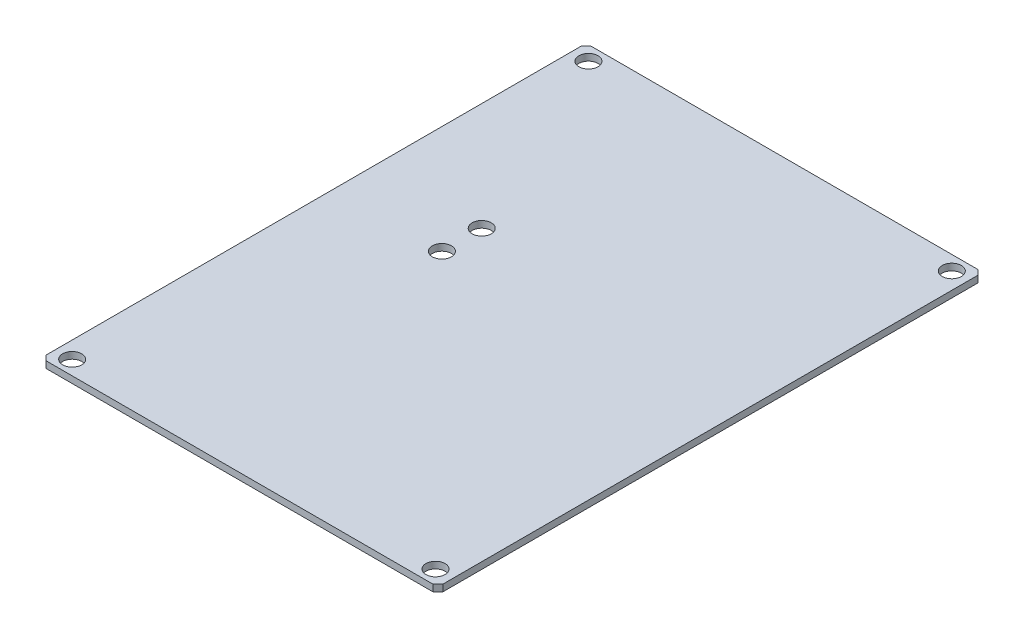
from build123d import *

# Parameters (mm, degrees)
BOSS_EXTRUDE1_DEPTH = 0.7
SKETCH5_R           = 1
CUT_EXTRUDE3_DEPTH  = 5
SKETCH6_R           = 1
CUT_EXTRUDE4_DEPTH  = 6


with BuildPart() as part:
    # Sketch1 → Boss-Extrude1 (new body)
    with BuildSketch(Plane(origin=(0, 0, 0), x_dir=(1, 0, 0), z_dir=(0, 1, 0))):
        Polygon((20.240139403, -28.5), (20.75, -27.990139403), (20.75, 27.990139403), (20.240139403, 28.5), (-20.240139403, 28.5), (-20.75, 27.990139403), (-20.75, -27.990139403), (-20.240139403, -28.5), align=None)
    extrude(amount=BOSS_EXTRUDE1_DEPTH)

    # Sketch5 → Cut-Extrude3 (cut)
    with BuildSketch(Plane(origin=(0, 0.7, 0), x_dir=(1, 0, 0), z_dir=(0, 1, 0))):
        with Locations((-19, 27)):
            Circle(SKETCH5_R)
        with Locations((19, 27)):
            Circle(SKETCH5_R)
        with Locations((19, -27)):
            Circle(SKETCH5_R)
        with Locations((-19, -27)):
            Circle(SKETCH5_R)
    extrude(amount=-CUT_EXTRUDE3_DEPTH, mode=Mode.SUBTRACT)

    # Sketch6 → Cut-Extrude4 (cut)
    with BuildSketch(Plane(origin=(0, 0.7, 0), x_dir=(1, 0, 0), z_dir=(0, 1, 0))):
        with Locations((-9.45, 6.284530189)):
            Circle(SKETCH6_R)
        with Locations((-9.45, 2.115469811)):
            Circle(SKETCH6_R)
    extrude(amount=-CUT_EXTRUDE4_DEPTH, mode=Mode.SUBTRACT)


solid = part.part
